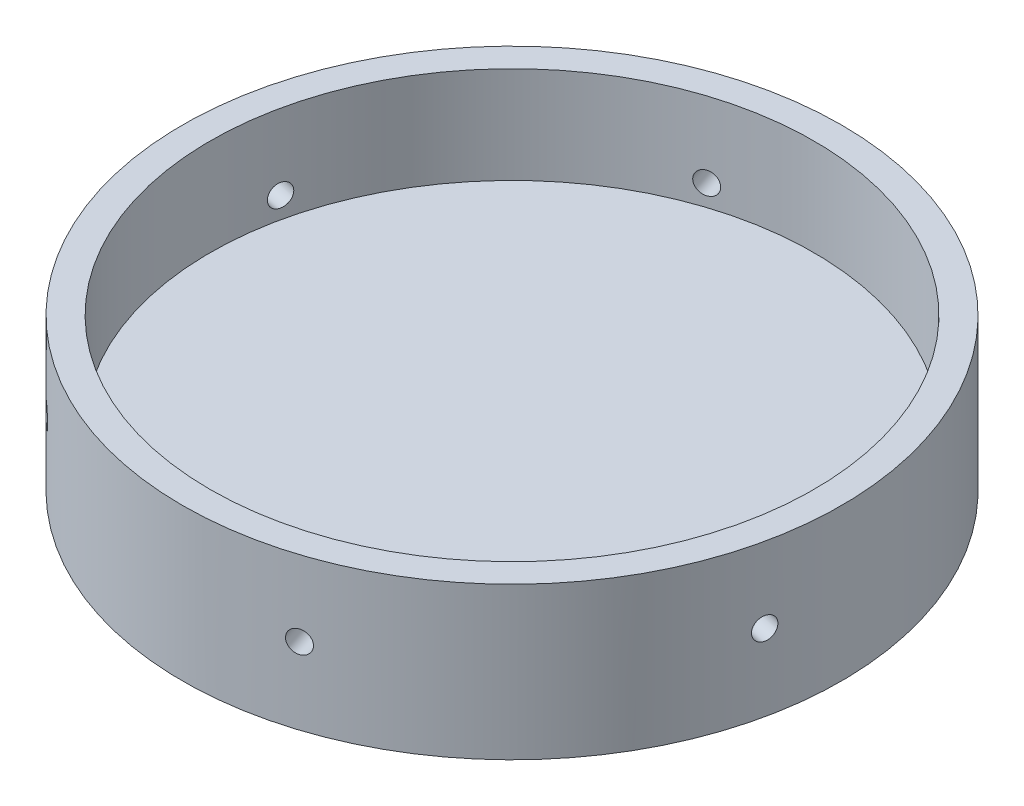
from build123d import *

# Parameters (mm, degrees)
SKETCH1_R                            = 75.692
SKETCH1_R_2                          = 69.342
BOSS_EXTRUDE1_DEPTH                  = 22.225
SKETCH2_R                            = 75.692
BOSS_EXTRUDE2_DEPTH                  = 12.7
TAP_DRILL_FOR_1_4_20_TAP1_AT_2_COUNT = 2
TAP_DRILL_FOR_1_4_20_TAP1_AT_2_PITCH = 53.488399339
CIRPATTERN1_COUNT                    = 6


with BuildPart() as part:
    # Sketch1 → Boss-Extrude1 (new body)
    with BuildSketch(Plane(origin=(0, 0, 0), x_dir=(1, 0, 0), z_dir=(0, 1, 0))):
        Circle(SKETCH1_R)
        Circle(SKETCH1_R_2, mode=Mode.SUBTRACT)
    extrude(amount=BOSS_EXTRUDE1_DEPTH)

    # Sketch2 → Boss-Extrude2 (add)
    with BuildSketch(Plane.XZ):
        Circle(SKETCH2_R)
    extrude(amount=BOSS_EXTRUDE2_DEPTH)

    # Sketch4 → Tap Drill for 1/4-20 Tap1 (revolve, cut)
    with BuildSketch(Plane(origin=(73.997176623, 4.896298223, 15.927859738), x_dir=(0.210429897, 0, -0.97760895), z_dir=(0, 1, 0))):
        Polygon((0, 0), (0, 11.185816902), (2.5527, 9.652), (2.5527, 0), align=None)
    tap_drill_for_1_4_20_tap1 = revolve(axis=Axis((80.204993454, 4.896298223, 17.264089582), (-0.97760895, 0, -0.210429897)), mode=Mode.SUBTRACT)

    # Tap Drill for 1/4-20 Tap1 at 2: Tap Drill for 1/4-20 Tap1 ×2
    with Locations(*[Vector(-0.110438581, 0.851210999, 0.51307227) * (i * TAP_DRILL_FOR_1_4_20_TAP1_AT_2_PITCH) for i in range(1, TAP_DRILL_FOR_1_4_20_TAP1_AT_2_COUNT)]):
        add(tap_drill_for_1_4_20_tap1, mode=Mode.SUBTRACT)

    # CirPattern1: Tap Drill for 1/4-20 Tap1 ×6 about axis
    cirpattern1_axis = Axis((0, 22.225, 0), (0, -1, 0))
    for i in range(1, CIRPATTERN1_COUNT):
        add(tap_drill_for_1_4_20_tap1.rotate(cirpattern1_axis, i * 360 / CIRPATTERN1_COUNT), mode=Mode.SUBTRACT)

    # CirPattern1 copy 1 sketch → CirPattern1 copy 1 (revolve, cut)
    with BuildSketch(Plane(origin=(-3.515628412, 50.426212075, 80.653301416), x_dir=(0.951849134, 0, -0.306566839), z_dir=(0, 1, 0))):
        Polygon((0, 0), (0, 11.185816902), (2.5527, 9.652), (2.5527, 0), align=None)
    revolve(axis=Axis((-1.568928987, 50.426212075, 86.697543415), (-0.306566839, 0, -0.951849134)), mode=Mode.SUBTRACT)

    # CirPattern1 copy 2 sketch → CirPattern1 copy 2 (revolve, cut)
    with BuildSketch(Plane(origin=(-71.605622131, 50.426212075, 37.282027193), x_dir=(0.741419237, 0, 0.671042111), z_dir=(0, 1, 0))):
        Polygon((0, 0), (0, 11.185816902), (2.5527, 9.652), (2.5527, 0), align=None)
    revolve(axis=Axis((-75.866739537, 50.426212075, 41.990039348), (0.671042111, 0, -0.741419237)), mode=Mode.SUBTRACT)

    # CirPattern1 copy 3 sketch → CirPattern1 copy 3 (revolve, cut)
    with BuildSketch(Plane(origin=(-68.089993719, 50.426212075, -43.371274223), x_dir=(-0.210429897, 0, 0.97760895), z_dir=(0, 1, 0))):
        Polygon((0, 0), (0, 11.185816902), (2.5527, 9.652), (2.5527, 0), align=None)
    revolve(axis=Axis((-74.29781055, 50.426212075, -44.707504067), (0.97760895, 0, 0.210429897)), mode=Mode.SUBTRACT)

    # CirPattern1 copy 4 sketch → CirPattern1 copy 4 (revolve, cut)
    with BuildSketch(Plane(origin=(3.515628412, 50.426212075, -80.653301416), x_dir=(-0.951849134, 0, 0.306566839), z_dir=(0, 1, 0))):
        Polygon((0, 0), (0, 11.185816902), (2.5527, 9.652), (2.5527, 0), align=None)
    revolve(axis=Axis((1.568928987, 50.426212075, -86.697543415), (0.306566839, 0, 0.951849134)), mode=Mode.SUBTRACT)

    # CirPattern1 copy 5 sketch → CirPattern1 copy 5 (revolve, cut)
    with BuildSketch(Plane(origin=(71.605622131, 50.426212075, -37.282027193), x_dir=(-0.741419237, 0, -0.671042111), z_dir=(0, 1, 0))):
        Polygon((0, 0), (0, 11.185816902), (2.5527, 9.652), (2.5527, 0), align=None)
    revolve(axis=Axis((75.866739537, 50.426212075, -41.990039348), (-0.671042111, 0, 0.741419237)), mode=Mode.SUBTRACT)


solid = part.part
